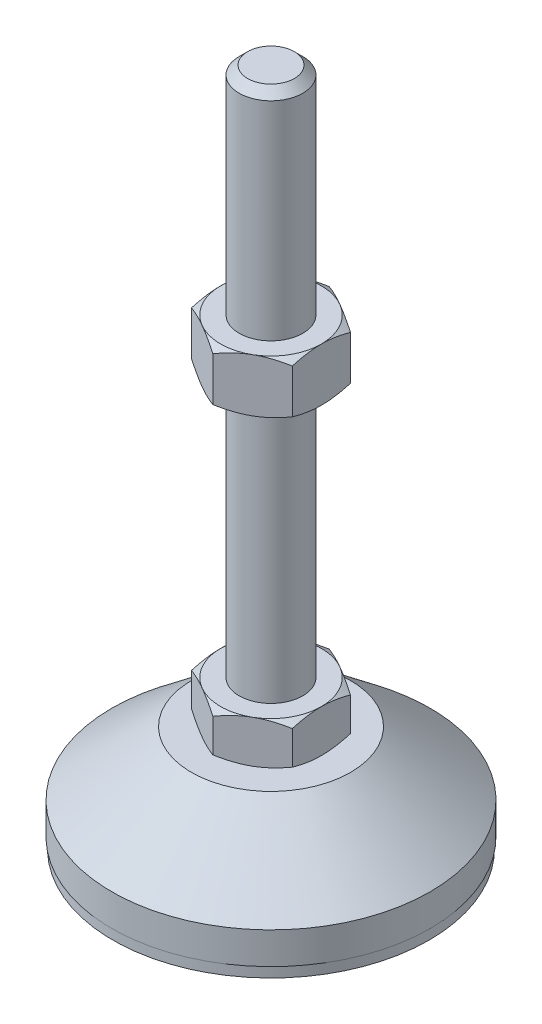
from build123d import *

# Parameters (mm, degrees)
EXTRUDE_1_DEPTH = 8
EXTRUDE_2_DEPTH = 10


with BuildPart() as part:
    # Эскиз1 → Повернуть1 (revolve)
    with BuildSketch(Plane.XY, mode=Mode.PRIVATE) as revolve_1_sk:
        Polygon((0, 0), (-29.8, 0), (-29.8, 2), (-30, 2), (-30, 8), (-15, 20), (-6, 20), (-6, 28), (-6, 126.4), (-4.4, 128), (0, 128), align=None)
    revolve(revolve_1_sk.sketch.rotate(Axis((0, 0, 0), (0, 1, 0)), 180), axis=Axis((0, 0, 0), (0, 1, 0)))  # turned: the seam where the file's is

    # Эскиз2 → Бобышка-Вытянуть1 (add)
    with BuildSketch(Plane(origin=(0, 20, 0), x_dir=(1, 0, 0), z_dir=(0, 1, 0))):
        Polygon((0, 10.969655115), (-9.5, 5.484827557), (-9.5, -5.484827557), (0, -10.969655115), (9.5, -5.484827557), (9.5, 5.484827557), align=None)
    extrude(amount=EXTRUDE_1_DEPTH)

    # Эскиз3 → Бобышка-Вытянуть2 (add)
    with BuildSketch(Plane(origin=(0, 77.2, 0), x_dir=(1, 0, 0), z_dir=(0, 1, 0))):
        Polygon((9.5, 5.484827557), (0, 10.969655115), (-9.5, 5.484827557), (-9.5, -5.484827557), (0, -10.969655115), (9.5, -5.484827557), align=None)
    extrude(amount=EXTRUDE_2_DEPTH)

    # Эскиз4 → Вырез-Повернуть2 (revolve, cut)
    with BuildSketch(Plane.XY, mode=Mode.PRIVATE) as cut_revolve_2_sk:
        Polygon((-18.160254038, 87.2), (-9.5, 87.2), (-18.160254038, 82.2), align=None)
        Polygon((-18.160254038, 77.2), (-18.160254038, 82.2), (-9.5, 77.2), align=None)
        Polygon((-16.42820323, 28), (-16.42820323, 24), (-9.5, 28), align=None)
        Polygon((-16.42820323, 24), (-16.42820323, 20), (-9.5, 20), align=None)
    revolve(cut_revolve_2_sk.sketch.rotate(Axis((0, 128, 0), (0, -1, 0)), 180), axis=Axis((0, 128, 0), (0, -1, 0)), mode=Mode.SUBTRACT)  # turned: the seam where the file's is


solid = part.part
